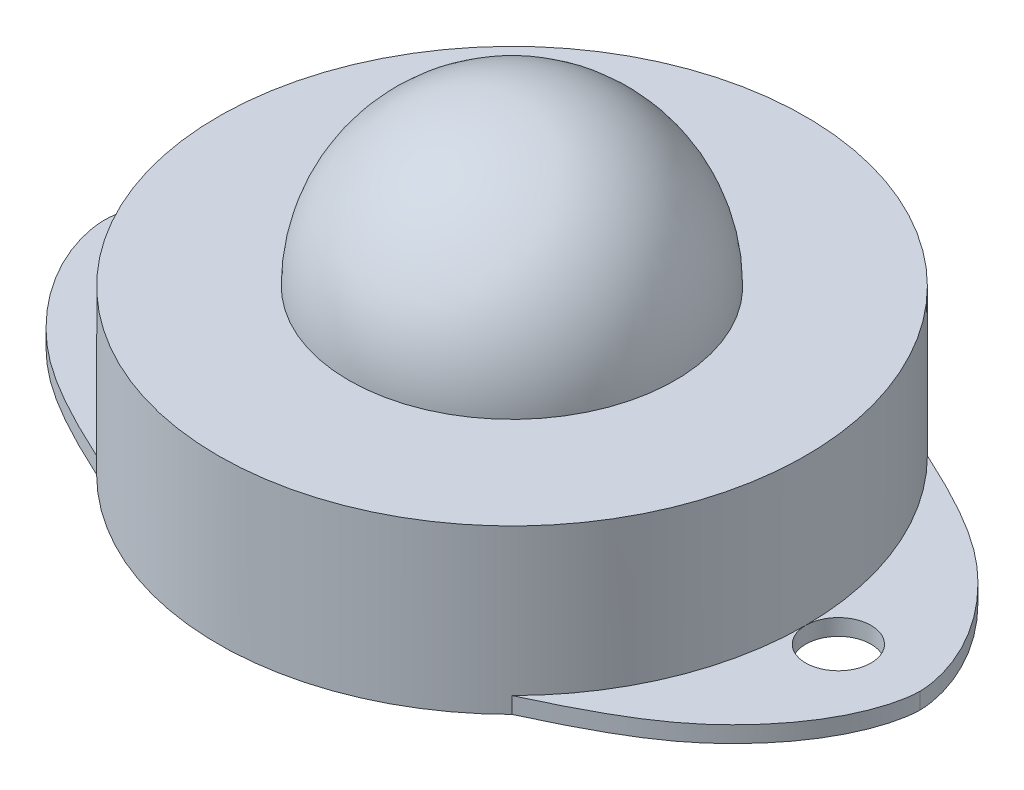
from build123d import *

# Parameters (mm, degrees)
SKETCH1_R            = 18
BOSS_EXTRUDE1_DEPTH  = 10
SKETCH2_R            = 2
BOSS_EXTRUDE11_DEPTH = 1
SKETCH3_R            = 2
CUT_EXTRUDE1_DEPTH   = 2


with BuildPart() as part:
    # Sketch1 → Boss-Extrude1 (new body)
    with BuildSketch(Plane(origin=(0, 0, 0), x_dir=(1, 0, 0), z_dir=(0, 1, 0))):
        with Locations(Location((0, 0, 0), (0, 0, 270))):
            Circle(SKETCH1_R)
    extrude(amount=BOSS_EXTRUDE1_DEPTH)

    # Sketch2 → Boss-Extrude11 (add)
    with BuildSketch(Plane.XZ):
        with BuildLine():
            ThreePointArc((-12.727922061, -12.727922061), (-16.629831585, -6.888301783), (-18, 0))
            ThreePointArc((-18, 0), (-16.629831585, 6.888301783), (-12.727922061, 12.727922061))
            add(Edge.make_bspline(
                [(-12.727922061, 12.727922061), (-17.413514116, 10.578941286), (-22.725992236, 6.653009013), (-24.419739959, 2.952843449), (-24.810237614, 1.3644098)],
                knots=[0, 0, 0, 0, 0.294966877, 0.815844303, 0.815844303, 0.815844303, 0.815844303], degree=3))
            add(Edge.make_bspline(
                [(-24.810237614, 1.3644098), (-24.948297671, 0.80282066), (-25, 0.337972177), (-25, 0)],
                knots=[0.815844303, 0.815844303, 0.815844303, 0.815844303, 1, 1, 1, 1], degree=3))
            add(Edge.make_bspline(
                [(-24.810237614, -1.3644098), (-24.948297671, -0.80282066), (-25, -0.337972177), (-25, 0)],
                knots=[0.815844303, 0.815844303, 0.815844303, 0.815844303, 1, 1, 1, 1], degree=3))
            add(Edge.make_bspline(
                [(-12.727922061, -12.727922061), (-17.413514116, -10.578941286), (-22.725992236, -6.653009013), (-24.419739959, -2.952843449), (-24.810237614, -1.3644098)],
                knots=[0, 0, 0, 0, 0.294966877, 0.815844303, 0.815844303, 0.815844303, 0.815844303], degree=3))
        make_face()
        with Locations((-20, 0)):
            Circle(SKETCH2_R, mode=Mode.SUBTRACT)
        with Locations((-20, 0)):
            Circle(SKETCH2_R)
        with BuildLine():
            ThreePointArc((12.727922061, 12.727922061), (16.629831585, 6.888301783), (18, 2e-09))
            ThreePointArc((18, 2e-09), (16.629831586, -6.888301782), (12.727922061, -12.727922061))
            add(Edge.make_bspline(
                [(12.727922061, -12.727922061), (17.413514116, -10.578941286), (23.925146422, -5.766831599), (25, -1.293913703), (25, 0)],
                knots=[0, 0, 0, 0, 0.294966877, 1, 1, 1, 1], degree=3))
            add(Edge.make_bspline(
                [(12.727922061, 12.727922061), (17.413514116, 10.578941286), (23.925146422, 5.766831599), (25, 1.293913703), (25, 0)],
                knots=[0, 0, 0, 0, 0.294966877, 1, 1, 1, 1], degree=3))
        make_face()
        with BuildLine():
            ThreePointArc((18, 2e-09), (20.000000001, 2), (22, 0))
            ThreePointArc((22, 0), (19.999999999, -2), (18, 2e-09))
        make_face(mode=Mode.SUBTRACT)
        with BuildLine():
            ThreePointArc((18, 2e-09), (19.999999999, -2), (22, 0))
            ThreePointArc((22, 0), (20.000000001, 2), (18, 2e-09))
        make_face()
    extrude(amount=-BOSS_EXTRUDE11_DEPTH)

    # Sketch3 → Cut-Extrude1 (cut)
    with BuildSketch(Plane.XZ):
        with Locations(Location((-20, 0, 0), (0, 0, 270))):
            Circle(SKETCH3_R)
        with Locations(Location((20, 0, 0), (0, 0, 270))):
            Circle(SKETCH3_R)
    extrude(amount=-CUT_EXTRUDE1_DEPTH, mode=Mode.SUBTRACT)

    # Sketch4 → Revolve1 (revolve)
    with BuildSketch(Plane(origin=(0, 10, 0), x_dir=(1, 0, 0), z_dir=(0, 1, 0))):
        with BuildLine():
            Line((0, 10), (0, -10))
            ThreePointArc((0, -10), (10, 0), (0, 10))
        make_face()
    revolve(axis=Axis((0, 10, -19.956600841), (0, 0, 1)))


solid = part.part
